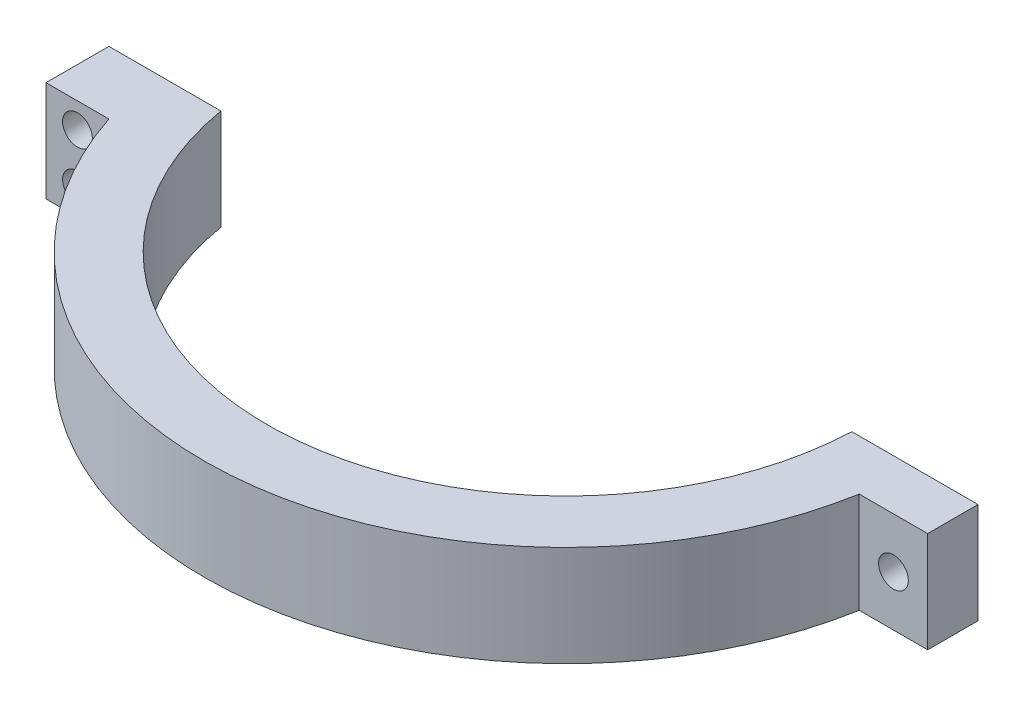
from build123d import *

# Parameters (mm, degrees)
BOSS_EXTRUDE1_DEPTH = 10.16
SKETCH2_R           = 1.5
CUT_EXTRUDE1_DEPTH  = 32.4325
SKETCH3_R           = 1.5
CUT_EXTRUDE2_DEPTH  = 7.35
SKETCH4_W           = 12.726748703
SKETCH4_H           = 1.27
CUT_EXTRUDE3_DEPTH  = 11.16


with BuildPart() as part:
    # Sketch1 → Boss-Extrude1 (new body)
    with BuildSketch(Plane(origin=(0, 0, 0), x_dir=(1, 0, 0), z_dir=(0, 1, 0))):
        with BuildLine():
            Line((0, 0), (-12.7, 0))
            ThreePointArc((-12.7, 0), (-40.313380236, -30.054590243), (-72.594133091, -5.08))
            Line((-72.594133091, -5.08), (-83.889837791, -5.08))
            Line((-83.889837791, -5.08), (-83.889837791, -11.43))
            Line((-83.889837791, -11.43), (-77.539837791, -11.43))
            ThreePointArc((-77.539837791, -11.43), (-40.243263553, -36.418432925), (-6.906413502, -6.35))
            Line((-6.906413502, -6.35), (0, -6.35))
            Line((0, -6.35), (0, 0))
        make_face()
    extrude(amount=BOSS_EXTRUDE1_DEPTH)

    # Sketch2 → Cut-Extrude1 (cut, through all)
    with BuildSketch(Plane(origin=(0, 0, 5.08), x_dir=(-1, 0, 0), z_dir=(0, 0, -1))):
        with Locations((80.714837791, 7.62)):
            Circle(SKETCH2_R)
        with Locations((80.714837791, 2.54)):
            Circle(SKETCH2_R)
    extrude(amount=-CUT_EXTRUDE1_DEPTH, mode=Mode.SUBTRACT)

    # Sketch3 → Cut-Extrude2 (cut, through all)
    with BuildSketch(Plane.XY.offset(6.35)):
        with Locations((-3.453206751, 5.08)):
            Circle(SKETCH3_R)
    extrude(amount=-CUT_EXTRUDE2_DEPTH, mode=Mode.SUBTRACT)

    # Sketch4 → Cut-Extrude3 (cut, through all)
    with BuildSketch(Plane.XZ):
        with Locations((-6.363374352, 0.635)):
            Rectangle(SKETCH4_W, SKETCH4_H)
    extrude(amount=-CUT_EXTRUDE3_DEPTH, mode=Mode.SUBTRACT)


solid = part.part
